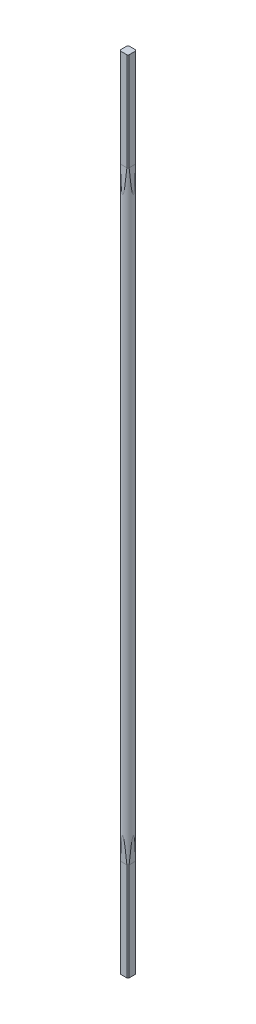
from build123d import *

# Parameters (mm, degrees)
BOSS_EXTRUDE1_DEPTH      = 245
BOSS_EXTRUDE1_DEPTH_BACK = 245
SKETCH1_R                = 3.3
SKETCH2_OUTSIDE_W        = 106.618
SKETCH2_OUTSIDE_H        = 106.618
SKETCH2_OUTSIDE_W_2      = 5.3
SKETCH2_OUTSIDE_H_2      = 5.3
CUT_EXTRUDE1_DEPTH       = 60
SKETCH3_OUTSIDE_W        = 107.928
SKETCH3_OUTSIDE_H        = 107.928
CUT_EXTRUDE2_DEPTH       = 15
CUT_EXTRUDE2_DRAFT       = -2.5
SKETCH4_OUTSIDE_W        = 106.618
SKETCH4_OUTSIDE_H        = 106.618
SKETCH4_OUTSIDE_W_2      = 5.3
SKETCH4_OUTSIDE_H_2      = 5.3
CUT_EXTRUDE3_DEPTH       = 60
SKETCH5_OUTSIDE_W        = 107.928
SKETCH5_OUTSIDE_H        = 107.928
CUT_EXTRUDE4_DEPTH       = 15
CUT_EXTRUDE4_DRAFT       = -2.5


with BuildPart() as part:
    # Sketch1 → Boss-Extrude1 (new, two sides: drawn at the far end of the back side and taken through both)
    with BuildSketch(Plane(origin=(0, 0, 0), x_dir=(1, 0, 0), z_dir=(0, 1, 0)).offset(-BOSS_EXTRUDE1_DEPTH_BACK)):
        Circle(SKETCH1_R)
    extrude(amount=BOSS_EXTRUDE1_DEPTH + BOSS_EXTRUDE1_DEPTH_BACK)

    # Sketch2 outside → Cut-Extrude1 (cut)
    with BuildSketch(Plane(origin=(0, 245, 0), x_dir=(1, 0, 0), z_dir=(0, 1, 0))):
        Rectangle(SKETCH2_OUTSIDE_W, SKETCH2_OUTSIDE_H)
        Rectangle(SKETCH2_OUTSIDE_W_2, SKETCH2_OUTSIDE_H_2, mode=Mode.SUBTRACT)
    extrude(amount=-CUT_EXTRUDE1_DEPTH, mode=Mode.SUBTRACT)


with BuildPart() as cut_extrude2_tool:
    # Sketch3 outside → Cut-Extrude2 (with draft: the straight prism first)
    with BuildSketch(Plane(origin=(0, 185, 0), x_dir=(1, 0, 0), z_dir=(0, 1, 0))):
        Rectangle(SKETCH3_OUTSIDE_W, SKETCH3_OUTSIDE_H)
        Polygon((-1.966596044, -2.65), (1.966596044, -2.65), (2.65, -2.65), (2.65, -1.966596044), (2.65, 1.966596044), (2.65, 2.65), (1.966596044, 2.65), (-1.966596044, 2.65), (-2.65, 2.65), (-2.65, 1.966596044), (-2.65, -1.966596044), (-2.65, -2.65), align=None, mode=Mode.SUBTRACT)
    extrude(amount=-CUT_EXTRUDE2_DEPTH)
    # Cut-Extrude2: the draft: its side faces are tilted about the plane it starts from
    cut_extrude2_sides = [cut_extrude2_tool.faces().sort_by_distance(p)[0] for p in [
        (0, 177.5, 53.964),
        (0, 177.5, 2.65),
        (2.65, 177.5, 0),
        (0, 177.5, -2.65),
        (-2.65, 177.5, 0),
        (0, 177.5, -53.964),
        (53.964, 177.5, 0),
        (-53.964, 177.5, 0),
    ]]
    draft(cut_extrude2_sides, Plane(origin=(0, 185, 0), x_dir=(1, 0, 0), z_dir=(0, 1, 0)), CUT_EXTRUDE2_DRAFT)


with BuildPart() as part_1:
    add(part.part)

    # Cut-Extrude2: cut by cut_extrude2_tool
    add(cut_extrude2_tool.part, mode=Mode.SUBTRACT)

    # Sketch4 outside → Cut-Extrude3 (cut)
    with BuildSketch(Plane.XZ.offset(245)):
        Rectangle(SKETCH4_OUTSIDE_W, SKETCH4_OUTSIDE_H)
        Rectangle(SKETCH4_OUTSIDE_W_2, SKETCH4_OUTSIDE_H_2, mode=Mode.SUBTRACT)
    extrude(amount=-CUT_EXTRUDE3_DEPTH, mode=Mode.SUBTRACT)


with BuildPart() as cut_extrude4_tool:
    # Sketch5 outside → Cut-Extrude4 (with draft: the straight prism first)
    with BuildSketch(Plane.XZ.offset(185)):
        Rectangle(SKETCH5_OUTSIDE_W, SKETCH5_OUTSIDE_H)
        Polygon((1.966596044, -2.65), (2.65, -2.65), (2.65, -1.966596044), (2.65, 1.966596044), (2.65, 2.65), (1.966596044, 2.65), (-1.966596044, 2.65), (-2.65, 2.65), (-2.65, 1.966596044), (-2.65, -1.966596044), (-2.65, -2.65), (-1.966596044, -2.65), align=None, mode=Mode.SUBTRACT)
    extrude(amount=-CUT_EXTRUDE4_DEPTH)
    # Cut-Extrude4: the draft: its side faces are tilted about the plane it starts from
    cut_extrude4_sides = [cut_extrude4_tool.faces().sort_by_distance(p)[0] for p in [
        (0, -177.5, -53.964),
        (0, -177.5, -2.65),
        (2.65, -177.5, 0),
        (0, -177.5, 2.65),
        (-2.65, -177.5, 0),
        (0, -177.5, 53.964),
        (53.964, -177.5, 0),
        (-53.964, -177.5, 0),
    ]]
    draft(cut_extrude4_sides, Plane.XZ.offset(185), CUT_EXTRUDE4_DRAFT)


with BuildPart() as part_2:
    add(part_1.part)

    # Cut-Extrude4: cut by cut_extrude4_tool
    add(cut_extrude4_tool.part, mode=Mode.SUBTRACT)


solid = part_2.part
